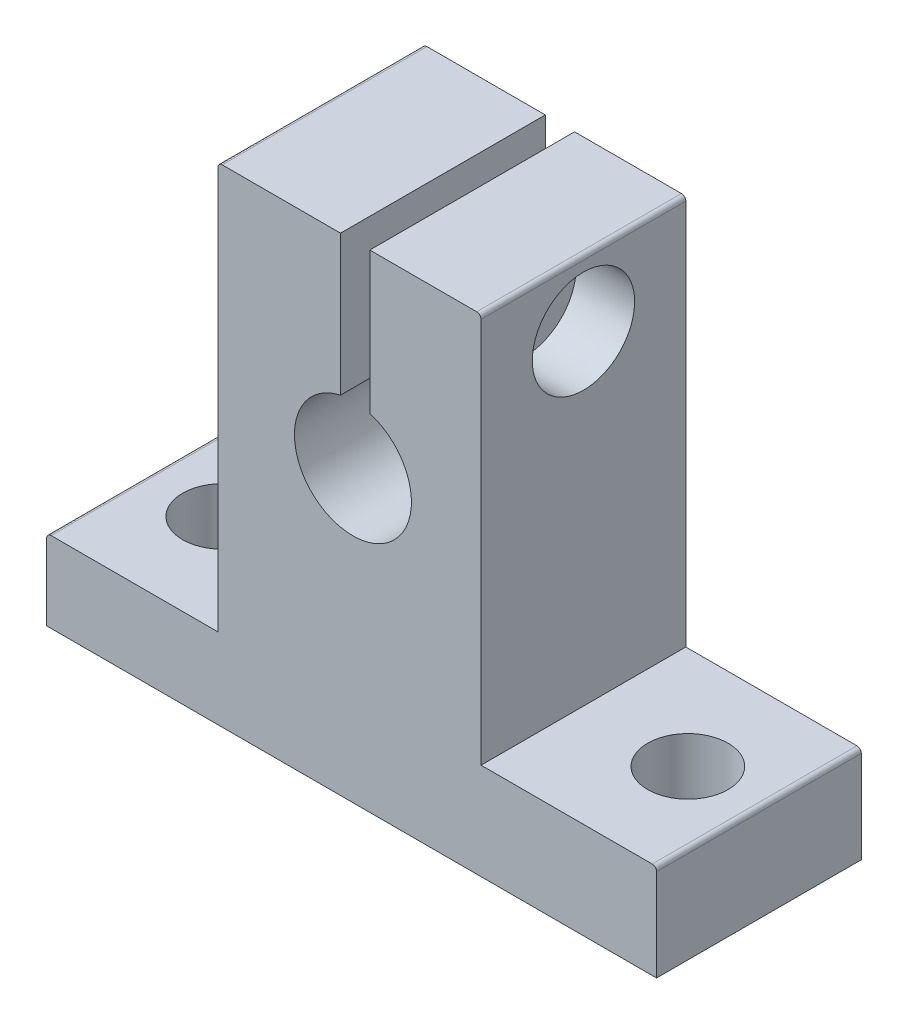
from build123d import *

# Parameters (mm, degrees)
SKETCH1_R           = 4
BOSS_EXTRUDE1_DEPTH = 14
SKETCH2_R           = 2.75
CUT_EXTRUDE1_DEPTH  = 6
SKETCH3_W           = 2
SKETCH3_H           = 11.620769134
CUT_EXTRUDE2_DEPTH  = 14
SKETCH4_R           = 2
CUT_EXTRUDE3_DEPTH  = 9
SKETCH5_R           = 3.5
CUT_EXTRUDE4_DEPTH  = 4
SKETCH6_R           = 1.85
CUT_EXTRUDE5_DEPTH  = 9
FILLET1_R           = 0.3


with BuildPart() as part:
    # Sketch1 → Boss-Extrude1 (new body)
    with BuildSketch(Plane.XY):
        Polygon((-20.938905162, 0.786403392), (-9.238905162, 0.786403392), (-9.238905162, 28.586403392), (8.761094838, 28.586403392), (8.761094838, 1.886403392), (20.761094838, 1.886403392), (20.761094838, -4.713596608), (-20.938905162, -4.713596608), align=None)
        with Locations((0, 15.086403392)):
            Circle(SKETCH1_R, mode=Mode.SUBTRACT)
    extrude(amount=BOSS_EXTRUDE1_DEPTH)

    # Sketch2 → Cut-Extrude1 (cut)
    with BuildSketch(Plane(origin=(0, 1.886403392, 0), x_dir=(1, 0, 0), z_dir=(0, 1, 0))):
        with Locations((-15.9, -7)):
            Circle(SKETCH2_R)
        with Locations((15.9, -7)):
            Circle(SKETCH2_R)
    extrude(amount=-CUT_EXTRUDE1_DEPTH, mode=Mode.SUBTRACT)

    # Sketch3 → Cut-Extrude2 (cut)
    with BuildSketch(Plane.XY.offset(14)):
        with Locations((0.152630001, 23.872597077)):
            Rectangle(SKETCH3_W, SKETCH3_H)
    extrude(amount=-CUT_EXTRUDE2_DEPTH, mode=Mode.SUBTRACT)

    # Sketch4 → Cut-Extrude3 (cut)
    with BuildSketch(Plane(origin=(8.761094838, 0, 0), x_dir=(0, 0, -1), z_dir=(1, 0, 0))):
        with Locations((-7, 24.086403392)):
            Circle(SKETCH4_R)
    extrude(amount=-CUT_EXTRUDE3_DEPTH, mode=Mode.SUBTRACT)

    # Sketch5 → Cut-Extrude4 (cut)
    with BuildSketch(Plane(origin=(8.761094838, 0, 0), x_dir=(0, 0, -1), z_dir=(1, 0, 0))):
        with Locations((-7, 24.086403392)):
            Circle(SKETCH5_R)
    extrude(amount=-CUT_EXTRUDE4_DEPTH, mode=Mode.SUBTRACT)

    # Sketch6 → Cut-Extrude5 (cut)
    with BuildSketch(Plane.ZY.offset(9.238905162)):
        with Locations((7, 24.086403392)):
            Circle(SKETCH6_R)
    extrude(amount=-CUT_EXTRUDE5_DEPTH, mode=Mode.SUBTRACT)

    # Fillet1
    fillet1_edges = [part.edges().sort_by_distance(p)[0] for p in [
        (-20.938905162, 0.786403392, 7),
        (-9.238905162, 28.586403392, 7),
        (8.761094838, 28.586403392, 7),
        (20.761094838, 1.886403392, 7),
    ]]
    fillet(fillet1_edges, radius=FILLET1_R)


solid = part.part
